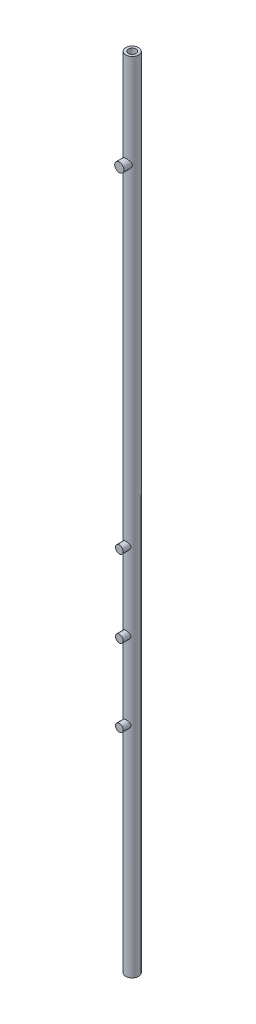
from build123d import *

# Parameters (mm, degrees)
SKETCH1_R           = 2.5
SKETCH1_R_2         = 1.5
BOSS_EXTRUDE1_DEPTH = 310
SKETCH2_R           = 1.503835311
BOSS_EXTRUDE2_DEPTH = 5
LPATTERN1_COUNT     = 3
LPATTERN1_PITCH     = 30
SKETCH3_R           = 1.791065429
BOSS_EXTRUDE3_DEPTH = 5


with BuildPart() as part:
    # Sketch1 → Boss-Extrude1 (new body)
    with BuildSketch(Plane(origin=(0, 0, 0), x_dir=(1, 0, 0), z_dir=(0, 1, 0))):
        Circle(SKETCH1_R)
        Circle(SKETCH1_R_2, mode=Mode.SUBTRACT)
    extrude(amount=BOSS_EXTRUDE1_DEPTH)

    # Sketch2 → Boss-Extrude2 (add)
    with BuildSketch(Plane.XY):
        with Locations((0, 84.914129816)):
            Circle(SKETCH2_R)
    boss_extrude2 = extrude(amount=BOSS_EXTRUDE2_DEPTH)

    # LPattern1: Boss-Extrude2 ×3
    with Locations(*[(0, i * LPATTERN1_PITCH, 0) for i in range(1, LPATTERN1_COUNT)]):
        add(boss_extrude2)

    # Sketch3 → Boss-Extrude3 (add)
    with BuildSketch(Plane.XY):
        with Locations((0, 273.450822339)):
            Circle(SKETCH3_R)
    extrude(amount=BOSS_EXTRUDE3_DEPTH)


solid = part.part
